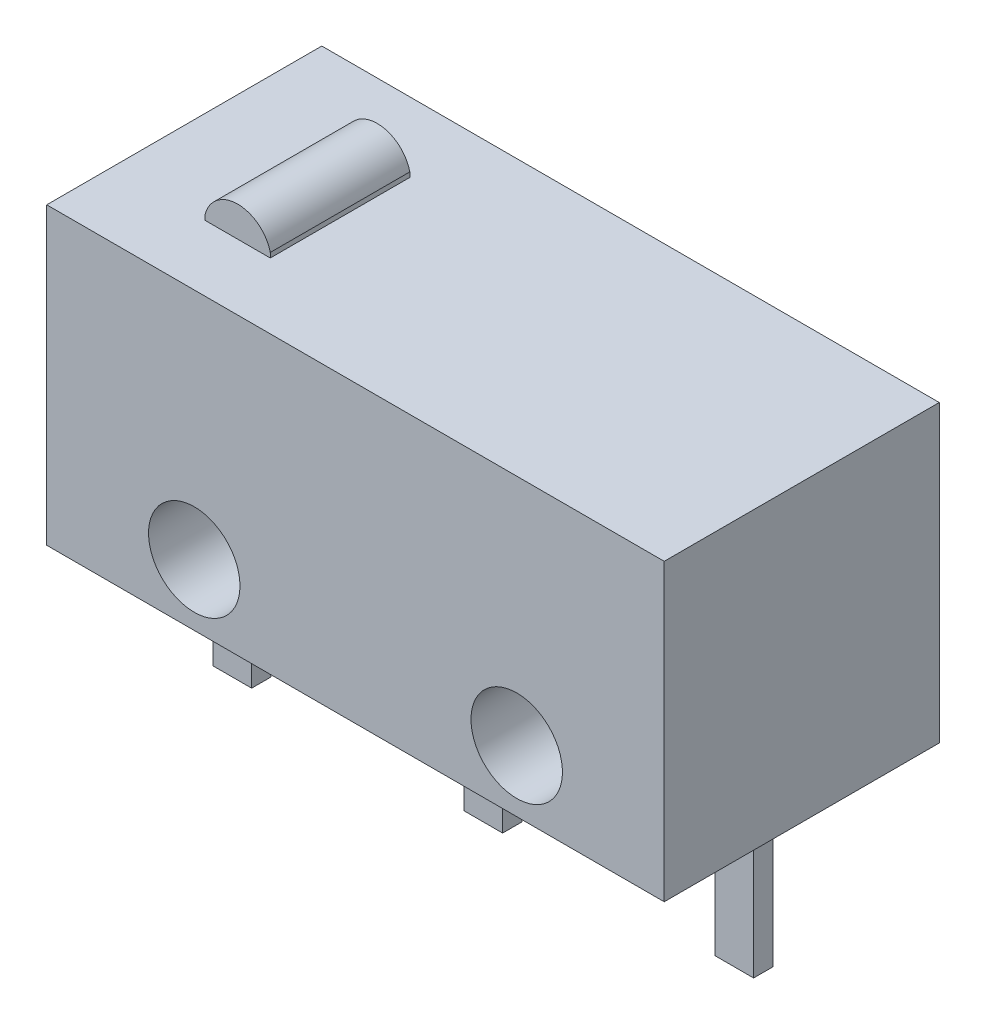
from build123d import *

# Parameters (mm, degrees)
SKETCH1_W          = 5.715
SKETCH1_H          = 6.127
EXTRUDE1_DEPTH     = 12.83
SKETCH2_R          = 0.95
CUT_EXTRUDE1_DEPTH = 20.8
SKETCH4_W          = 0.8
SKETCH4_H          = 0.4
EXTRUDE2_DEPTH     = 3.1
EXTRUDE5_DEPTH     = 2.9


with BuildPart() as part:
    # Sketch1 → Extrude1 (new body)
    with BuildSketch(Plane(origin=(3.15, 0, 0), x_dir=(0, 0, -1), z_dir=(1, 0, 0))):
        with Locations((0.0425, 1.5635)):
            Rectangle(SKETCH1_W, SKETCH1_H)
    extrude(amount=-EXTRUDE1_DEPTH)

    # Sketch2 → Cut-Extrude1 (cut)
    with BuildSketch(Plane.XY.offset(2.815)):
        with Locations((0.085, -0.223)):
            Circle(SKETCH2_R)
        with Locations((-6.615, -0.223)):
            Circle(SKETCH2_R)
    extrude(amount=-CUT_EXTRUDE1_DEPTH, mode=Mode.SUBTRACT)

    # Sketch4 → Extrude2 (add)
    with BuildSketch(Plane.XZ.offset(1.5)):
        with Locations((-8.48, -0.0425)):
            Rectangle(SKETCH4_W, SKETCH4_H)
        with Locations((-3.265, -0.0425)):
            Rectangle(SKETCH4_W, SKETCH4_H)
        with Locations((1.95, -0.0425)):
            Rectangle(SKETCH4_W, SKETCH4_H)
    extrude(amount=EXTRUDE2_DEPTH)

    # Sketch7 → Extrude5 (add)
    with BuildSketch(Plane(origin=(0, 0, -1.45), x_dir=(-1, 0, 0), z_dir=(0, 0, -1))):
        with BuildLine():
            Line((7.755679036, 4.627), (6.400179952, 4.627))
            Line((6.400179952, 4.627), (6.400179952, 4.727))
            ThreePointArc((6.400179952, 4.727), (7.077929494, 5.259200233), (7.755679036, 4.727))
            Line((7.755679036, 4.727), (7.755679036, 4.627))
        make_face()
    extrude(amount=-EXTRUDE5_DEPTH)


solid = part.part
